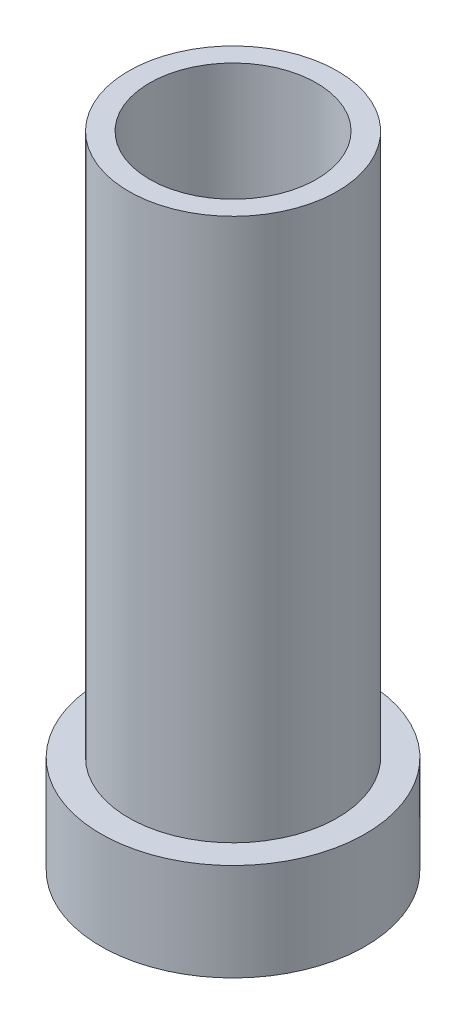
from build123d import *

# Parameters (mm, degrees)
SKETCH_2_R          = 3
CUT_EXTRUDE_1_DEPTH = 10
SKETCH_3_R          = 2
CUT_EXTRUDE_2_DEPTH = 24


with BuildPart() as part:
    # Эскиз1 → Повернуть1 (revolve)
    with BuildSketch(Plane.XY):
        Polygon((3.75, 23), (3.75, 3.5), (4.75, 3.5), (4.75, 0), (0, 0), (0, 23), align=None)
    revolve(axis=Axis((0, 0, 0), (0, 1, 0)))

    # Эскиз2 → Вырез-Вытянуть1 (cut)
    with BuildSketch(Plane(origin=(0, 23, 0), x_dir=(1, 0, 0), z_dir=(0, 1, 0))):
        Circle(SKETCH_2_R)
    extrude(amount=-CUT_EXTRUDE_1_DEPTH, mode=Mode.SUBTRACT)

    # Эскиз3 → Вырез-Вытянуть2 (cut, through all)
    with BuildSketch(Plane.XZ):
        Circle(SKETCH_3_R)
    extrude(amount=-CUT_EXTRUDE_2_DEPTH, mode=Mode.SUBTRACT)


solid = part.part
